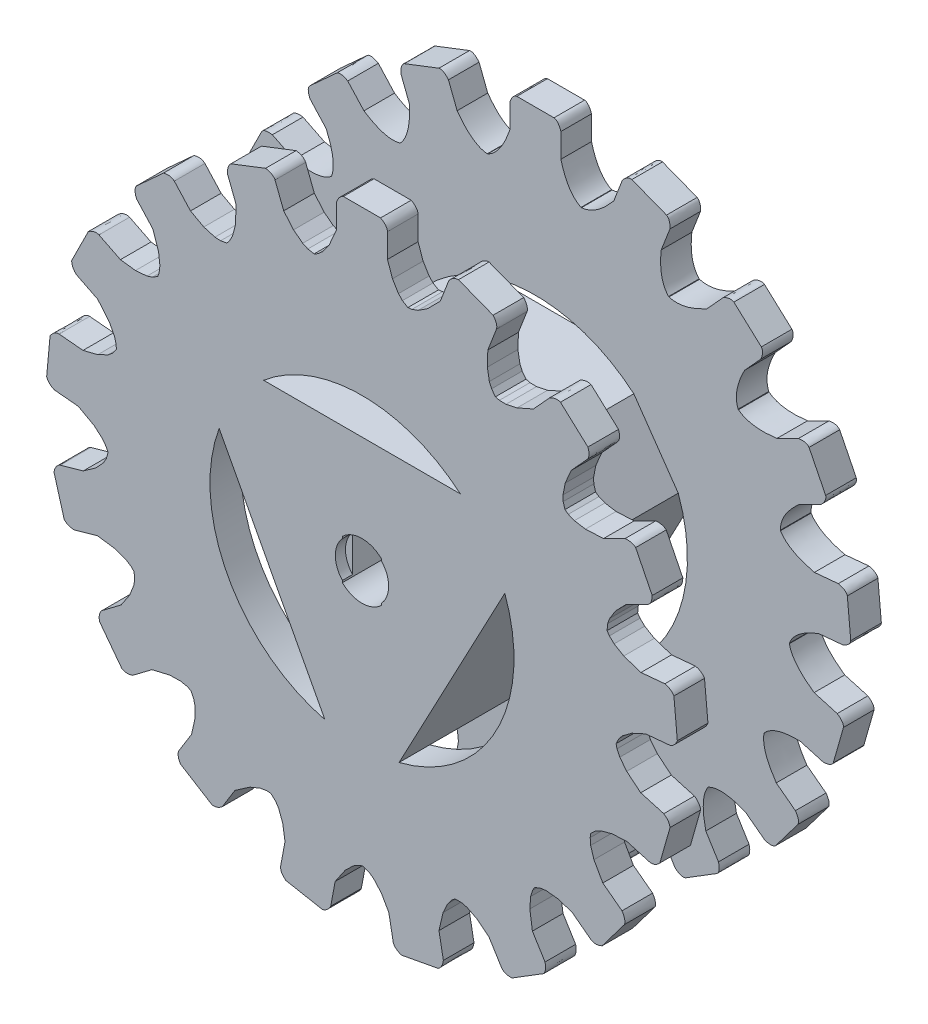
from build123d import *

# Parameters (mm, degrees)
BOSS_EXTRUDE2_DEPTH  = 3
BOSS_EXTRUDE3_DEPTH  = 14
BOSS_EXTRUDE7_DEPTH  = 3
BOSS_EXTRUDE10_DEPTH = 5
CUT_EXTRUDE2_DEPTH   = 6.8
SKETCH7_R            = 2.616026973
CUT_EXTRUDE3_DEPTH   = 1


with BuildPart() as part:
    # Sketch1 → Boss-Extrude2 (new body)
    with BuildSketch(Plane.XY):
        with BuildLine():
            Line((8.523768733, 28.922958261), (7.673117692, 26.727174809))
            add(Edge.make_bspline(
                [(7.673117692, 26.727174809), (5.977966967, 24.70445358), (4.514634253, 24.588982849)],
                knots=[0, 0, 0, 0.37277567, 0.37277567, 0.37277567], degree=2))
            ThreePointArc((4.514634253, 24.588982849), (4.492443696, 24.593046774), (4.470249482, 24.597090673))
            add(Edge.make_bspline(
                [(2.5, 27.6941981), (3.147445202, 25.23338067), (4.470249482, 24.597090673)],
                knots=[0, 0, 0, 0.37277567, 0.37277567, 0.37277567], degree=2))
            Line((2.5, 27.6941981), (2.5, 30.04899579))
            add(Edge.make_bspline(
                [(2.5, 30.04899579), (2.258646097, 30.79207266), (1.822349431, 30.874685911)],
                knots=[0, 0, 0, 0.57378329, 0.57378329, 0.57378329], degree=2))
            Line((1.822349431, 30.874685911), (-1.822349431, 30.874685911))
            add(Edge.make_bspline(
                [(-2.5, 30.04899579), (-2.258646161, 30.79207266), (-1.822349431, 30.874685911)],
                knots=[0, 0, 0, 0.573783349, 0.573783349, 0.573783349], degree=2))
            Line((-2.5, 30.04899579), (-2.5, 27.6941981))
            add(Edge.make_bspline(
                [(-2.5, 27.6941981), (-3.349989788, 25.195707653), (-4.672794068, 24.559417656)],
                knots=[0, 0, 0, 0.37277567, 0.37277567, 0.37277567], degree=2))
            ThreePointArc((-4.672794068, 24.559417656), (-4.694954204, 24.555190999), (-4.717110518, 24.550944348))
            add(Edge.make_bspline(
                [(-7.673117692, 26.727174809), (-6.180443233, 24.666415078), (-4.717110518, 24.550944348)],
                knots=[0, 0, 0, 0.37277567, 0.37277567, 0.37277567], degree=2))
            Line((-7.673117692, 26.727174809), (-8.523768733, 28.922958261))
            add(Edge.make_bspline(
                [(-8.523768733, 28.922958261), (-9.017254872, 29.528669721), (-9.453932744, 29.448095748)],
                knots=[0, 0, 0, 0.57378329, 0.57378329, 0.57378329], degree=2))
            Line((-9.453932744, 29.448095748), (-12.852513218, 28.131478658))
            add(Edge.make_bspline(
                [(-13.18612988, 27.11674993), (-13.229504455, 27.896835539), (-12.852513218, 28.131478658)],
                knots=[0, 0, 0, 0.573783349, 0.573783349, 0.573783349], degree=2))
            Line((-13.18612988, 27.11674993), (-12.335478839, 24.920966478))
            add(Edge.make_bspline(
                [(-12.335478839, 24.920966478), (-12.22551186, 22.284141794), (-13.229135657, 21.21296702)],
                knots=[0, 0, 0, 0.37277567, 0.37277567, 0.37277567], degree=2))
            ThreePointArc((-13.229135657, 21.21296702), (-13.248272524, 21.201020615), (-13.267398604, 21.189056947))
            add(Edge.make_bspline(
                [(-16.809938321, 22.15049846), (-14.673628561, 20.768113448), (-13.267398604, 21.189056947)],
                knots=[0, 0, 0, 0.37277567, 0.37277567, 0.37277567], degree=2))
            Line((-16.809938321, 22.15049846), (-18.396355267, 23.890714952))
            add(Edge.make_bspline(
                [(-18.396355267, 23.890714952), (-19.075325604, 24.277256312), (-19.453408917, 24.044377078)],
                knots=[0, 0, 0, 0.57378329, 0.57378329, 0.57378329], degree=2))
            Line((-19.453408917, 24.044377078), (-22.146873877, 21.588959331))
            add(Edge.make_bspline(
                [(-22.091399853, 20.522236733), (-22.413644864, 21.233976197), (-22.146873877, 21.588959331)],
                knots=[0, 0, 0, 0.573783349, 0.573783349, 0.573783349], degree=2))
            Line((-22.091399853, 20.522236733), (-20.504982907, 18.782020242))
            add(Edge.make_bspline(
                [(-20.504982907, 18.782020242), (-19.449910811, 16.362979105), (-19.99880917, 15.001587642)],
                knots=[0, 0, 0, 0.37277567, 0.37277567, 0.37277567], degree=2))
            ThreePointArc((-19.99880917, 15.001587642), (-20.012338228, 14.983534918), (-20.025850991, 14.965469993))
            add(Edge.make_bspline(
                [(-23.676483633, 14.582274554), (-21.185059044, 14.064963017), (-20.025850991, 14.965469993)],
                knots=[0, 0, 0, 0.37277567, 0.37277567, 0.37277567], degree=2))
            Line((-23.676483633, 14.582274554), (-25.784412084, 15.631898205))
            add(Edge.make_bspline(
                [(-25.784412084, 15.631898205), (-26.557167913, 15.747064912), (-26.82559442, 15.393332048)],
                knots=[0, 0, 0, 0.57378329, 0.57378329, 0.57378329], degree=2))
            Line((-26.82559442, 15.393332048), (-28.450176499, 12.130731418))
            add(Edge.make_bspline(
                [(-28.013103863, 11.156081748), (-28.570698337, 11.703350707), (-28.450176499, 12.130731418)],
                knots=[0, 0, 0, 0.573783349, 0.573783349, 0.573783349], degree=2))
            Line((-28.013103863, 11.156081748), (-25.905175412, 10.106458097))
            add(Edge.make_bspline(
                [(-25.905175412, 10.106458097), (-24.047491531, 8.231905417), (-24.067532687, 6.764160727)],
                knots=[0, 0, 0, 0.37277567, 0.37277567, 0.37277567], degree=2))
            ThreePointArc((-24.067532687, 6.764160727), (-24.073626762, 6.742439803), (-24.079701234, 6.720713389))
            add(Edge.make_bspline(
                [(-27.345388634, 5.044633666), (-24.835329912, 5.462261394), (-24.079701234, 6.720713389)],
                knots=[0, 0, 0, 0.37277567, 0.37277567, 0.37277567], degree=2))
            Line((-27.345388634, 5.044633666), (-29.690141173, 5.261906986))
            add(Edge.make_bspline(
                [(-29.690141173, 5.261906986), (-30.452317537, 5.090145139), (-30.574834751, 4.663332228)],
                knots=[0, 0, 0, 0.57378329, 0.57378329, 0.57378329], degree=2))
            Line((-30.574834751, 4.663332228), (-30.911125136, 1.034181008))
            add(Edge.make_bspline(
                [(-30.15148297, 0.283236104), (-30.869120683, 0.592122854), (-30.911125136, 1.034181008)],
                knots=[0, 0, 0, 0.573783349, 0.573783349, 0.573783349], degree=2))
            Line((-30.15148297, 0.283236104), (-27.806730432, 0.065962785))
            add(Edge.make_bspline(
                [(-27.806730432, 0.065962785), (-25.397325268, -1.010932712), (-24.885802553, -2.386803576)],
                knots=[0, 0, 0, 0.37277567, 0.37277567, 0.37277567], degree=2))
            ThreePointArc((-24.885802553, -2.386803576), (-24.883638606, -2.409259168), (-24.881454396, -2.431712798))
            add(Edge.make_bspline(
                [(-27.321147375, -5.174312952), (-25.131451858, -3.878148898), (-24.881454396, -2.431712798)],
                knots=[0, 0, 0, 0.37277567, 0.37277567, 0.37277567], degree=2))
            Line((-27.321147375, -5.174312952), (-29.586052178, -5.818733929))
            add(Edge.make_bspline(
                [(-29.586052178, -5.818733929), (-30.234712936, -6.25422694), (-30.194774228, -6.69647645)],
                knots=[0, 0, 0, 0.57378329, 0.57378329, 0.57378329], degree=2))
            Line((-30.194774228, -6.69647645), (-29.19735504, -10.202041278))
            add(Edge.make_bspline(
                [(-28.217737227, -10.627862145), (-28.998497229, -10.599074471), (-29.19735504, -10.202041278)],
                knots=[0, 0, 0, 0.573783349, 0.573783349, 0.573783349], degree=2))
            Line((-28.217737227, -10.627862145), (-25.952832424, -9.983441168))
            add(Edge.make_bspline(
                [(-25.952832424, -9.983441168), (-23.317109497, -10.117238776), (-22.343106886, -11.21541683)],
                knots=[0, 0, 0, 0.37277567, 0.37277567, 0.37277567], degree=2))
            ThreePointArc((-22.343106886, -11.21541683), (-22.33297717, -11.235574338), (-22.322829269, -11.255722697))
            add(Edge.make_bspline(
                [(-23.60703377, -14.694439933), (-22.033431972, -12.694793692), (-22.322829269, -11.255722697)],
                knots=[0, 0, 0, 0.37277567, 0.37277567, 0.37277567], degree=2))
            Line((-23.60703377, -14.694439933), (-25.486202894, -16.113522583))
            add(Edge.make_bspline(
                [(-25.486202894, -16.113522583), (-25.933742816, -16.753931016), (-25.736742131, -17.151888877)],
                knots=[0, 0, 0, 0.57378329, 0.57378329, 0.57378329], degree=2))
            Line((-25.736742131, -17.151888877), (-23.540320357, -20.060421358))
            add(Edge.make_bspline(
                [(-22.473029712, -20.10360872), (-23.211466039, -20.358808058), (-23.540320357, -20.060421358)],
                knots=[0, 0, 0, 0.573783349, 0.573783349, 0.573783349], degree=2))
            Line((-22.473029712, -20.10360872), (-20.593860588, -18.68452607))
            add(Edge.make_bspline(
                [(-20.593860588, -18.68452607), (-18.087788883, -17.857155682), (-16.782850827, -18.529325895)],
                knots=[0, 0, 0, 0.37277567, 0.37277567, 0.37277567], degree=2))
            ThreePointArc((-16.782850827, -18.529325895), (-16.766123417, -18.544462936), (-16.749382354, -18.559584876))
            add(Edge.make_bspline(
                [(-16.704659444, -22.230001378), (-15.959675007, -19.796936253), (-16.749382354, -18.559584876)],
                knots=[0, 0, 0, 0.37277567, 0.37277567, 0.37277567], degree=2))
            Line((-16.704659444, -22.230001378), (-17.944300685, -24.232090725))
            add(Edge.make_bspline(
                [(-17.944300685, -24.232090725), (-18.130277025, -24.990923871), (-17.802820396, -25.290843669)],
                knots=[0, 0, 0, 0.57378329, 0.57378329, 0.57378329], degree=2))
            Line((-17.802820396, -25.290843669), (-14.704034968, -27.209530374))
            add(Edge.make_bspline(
                [(-13.693215007, -26.864251539), (-14.28959774, -27.368971804), (-14.704034968, -27.209530374)],
                knots=[0, 0, 0, 0.573783349, 0.573783349, 0.573783349], degree=2))
            Line((-13.693215007, -26.864251539), (-12.453573765, -24.862162192))
            add(Edge.make_bspline(
                [(-12.453573765, -24.862162192), (-10.415612153, -23.185364764), (-8.955977767, -23.340746822)],
                knots=[0, 0, 0, 0.37277567, 0.37277567, 0.37277567], degree=2))
            ThreePointArc((-8.955977767, -23.340746822), (-8.934911792, -23.348819055), (-8.91383854, -23.356872275))
            add(Edge.make_bspline(
                [(-7.546228296, -26.763277955), (-7.730475497, -24.225392875), (-8.91383854, -23.356872275)],
                knots=[0, 0, 0, 0.37277567, 0.37277567, 0.37277567], degree=2))
            Line((-7.546228296, -26.763277955), (-7.978921236, -29.07798074))
            add(Edge.make_bspline(
                [(-7.978921236, -29.07798074), (-7.878216859, -29.852753978), (-7.464529118, -30.014129882)],
                knots=[0, 0, 0, 0.57378329, 0.57378329, 0.57378329], degree=2))
            Line((-7.464529118, -30.014129882), (-3.88188818, -30.683841541))
            add(Edge.make_bspline(
                [(-3.064055738, -29.996728329), (-3.437840086, -30.682804252), (-3.88188818, -30.683841541)],
                knots=[0, 0, 0, 0.573783349, 0.573783349, 0.573783349], degree=2))
            Line((-3.064055738, -29.996728329), (-2.631362798, -27.682025544))
            add(Edge.make_bspline(
                [(-2.631362798, -27.682025544), (-1.336749286, -25.382261859), (0.080449717, -24.999870557)],
                knots=[0, 0, 0, 0.37277567, 0.37277567, 0.37277567], degree=2))
            ThreePointArc((0.080449717, -24.999870557), (0.103009181, -24.999787781), (0.125568562, -24.999684649))
            add(Edge.make_bspline(
                [(2.631362798, -27.682025544), (1.542767565, -25.382075951), (0.125568562, -24.999684649)],
                knots=[0, 0, 0, 0.37277567, 0.37277567, 0.37277567], degree=2))
            Line((2.631362798, -27.682025544), (3.064055738, -29.996728329))
            add(Edge.make_bspline(
                [(3.064055738, -29.996728329), (3.437840149, -30.68280424), (3.88188818, -30.683841541)],
                knots=[0, 0, 0, 0.57378329, 0.57378329, 0.57378329], degree=2))
            Line((3.88188818, -30.683841541), (7.464529118, -30.014129882))
            add(Edge.make_bspline(
                [(7.978921237, -29.07798074), (7.878216922, -29.852753966), (7.464529118, -30.014129882)],
                knots=[0, 0, 0, 0.573783349, 0.573783349, 0.573783349], degree=2))
            Line((7.978921237, -29.07798074), (7.546228296, -26.763277955))
            add(Edge.make_bspline(
                [(7.546228296, -26.763277955), (7.922648978, -24.151143843), (9.106012021, -23.282623243)],
                knots=[0, 0, 0, 0.37277567, 0.37277567, 0.37277567], degree=2))
            ThreePointArc((9.106012021, -23.282623243), (9.127018193, -23.274396639), (9.148016933, -23.266151082))
            add(Edge.make_bspline(
                [(12.453573766, -24.862162192), (10.607651319, -23.110769024), (9.148016933, -23.266151082)],
                knots=[0, 0, 0, 0.37277567, 0.37277567, 0.37277567], degree=2))
            Line((12.453573766, -24.862162192), (13.693215007, -26.864251539))
            add(Edge.make_bspline(
                [(13.693215007, -26.864251539), (14.289597795, -27.36897177), (14.704034968, -27.209530374)],
                knots=[0, 0, 0, 0.57378329, 0.57378329, 0.57378329], degree=2))
            Line((14.704034968, -27.209530374), (17.802820396, -25.290843669))
            add(Edge.make_bspline(
                [(17.944300685, -24.232090725), (18.13027708, -24.990923837), (17.802820396, -25.290843669)],
                knots=[0, 0, 0, 0.573783349, 0.573783349, 0.573783349], degree=2))
            Line((17.944300685, -24.232090725), (16.704659444, -22.230001378))
            add(Edge.make_bspline(
                [(16.704659444, -22.230001378), (16.112049598, -19.658280024), (16.901756944, -18.420928647)],
                knots=[0, 0, 0, 0.37277567, 0.37277567, 0.37277567], degree=2))
            ThreePointArc((16.901756944, -18.420928647), (16.918372824, -18.405669262), (16.934974927, -18.39039489))
            add(Edge.make_bspline(
                [(20.593860588, -18.68452607), (18.239912983, -17.718224678), (16.934974927, -18.39039489)],
                knots=[0, 0, 0, 0.37277567, 0.37277567, 0.37277567], degree=2))
            Line((20.593860588, -18.68452607), (22.473029712, -20.10360872))
            add(Edge.make_bspline(
                [(22.473029712, -20.10360872), (23.211466078, -20.358808006), (23.540320357, -20.060421357)],
                knots=[0, 0, 0, 0.57378329, 0.57378329, 0.57378329], degree=2))
            Line((23.540320357, -20.060421357), (25.736742131, -17.151888877))
            add(Edge.make_bspline(
                [(25.486202894, -16.113522583), (25.933742855, -16.753930964), (25.736742131, -17.151888877)],
                knots=[0, 0, 0, 0.573783349, 0.573783349, 0.573783349], degree=2))
            Line((25.486202894, -16.113522583), (23.60703377, -14.694439933))
            add(Edge.make_bspline(
                [(23.60703377, -14.694439933), (22.125428639, -12.510456558), (22.414825935, -11.071385563)],
                knots=[0, 0, 0, 0.37277567, 0.37277567, 0.37277567], degree=2))
            ThreePointArc((22.414825935, -11.071385563), (22.424807457, -11.051154263), (22.434770717, -11.030913963))
            add(Edge.make_bspline(
                [(25.952832424, -9.983441168), (23.408773328, -9.93273591), (22.434770717, -11.030913963)],
                knots=[0, 0, 0, 0.37277567, 0.37277567, 0.37277567], degree=2))
            Line((25.952832424, -9.983441168), (28.217737227, -10.627862145))
            add(Edge.make_bspline(
                [(28.217737227, -10.627862145), (28.998497247, -10.599074409), (29.19735504, -10.202041278)],
                knots=[0, 0, 0, 0.57378329, 0.57378329, 0.57378329], degree=2))
            Line((29.19735504, -10.202041278), (30.194774228, -6.69647645))
            add(Edge.make_bspline(
                [(29.586052178, -5.818733929), (30.234712953, -6.254226878), (30.194774228, -6.69647645)],
                knots=[0, 0, 0, 0.573783349, 0.573783349, 0.573783349], degree=2))
            Line((29.586052178, -5.818733929), (27.321147375, -5.174312952))
            add(Edge.make_bspline(
                [(27.321147375, -5.174312952), (25.150645941, -3.673026611), (24.900648479, -2.22659051)],
                knots=[0, 0, 0, 0.37277567, 0.37277567, 0.37277567], degree=2))
            ThreePointArc((24.900648479, -2.22659051), (24.902647582, -2.204119643), (24.904626407, -2.181646981))
            add(Edge.make_bspline(
                [(27.806730432, 0.065962785), (25.416149122, -0.805776117), (24.904626407, -2.181646981)],
                knots=[0, 0, 0, 0.37277567, 0.37277567, 0.37277567], degree=2))
            Line((27.806730432, 0.065962785), (30.15148297, 0.283236104))
            add(Edge.make_bspline(
                [(30.15148297, 0.283236104), (30.869120677, 0.592122918), (30.911125136, 1.034181008)],
                knots=[0, 0, 0, 0.57378329, 0.57378329, 0.57378329], degree=2))
            Line((30.911125136, 1.034181008), (30.574834751, 4.663332228))
            add(Edge.make_bspline(
                [(29.690141173, 5.261906986), (30.452317531, 5.090145204), (30.574834751, 4.663332228)],
                knots=[0, 0, 0, 0.573783349, 0.573783349, 0.573783349], degree=2))
            Line((29.690141173, 5.261906986), (27.345388634, 5.044633666))
            add(Edge.make_bspline(
                [(27.345388634, 5.044633666), (24.779129144, 5.660465933), (24.023500467, 6.918917929)],
                knots=[0, 0, 0, 0.37277567, 0.37277567, 0.37277567], degree=2))
            ThreePointArc((24.023500467, 6.918917929), (24.017247161, 6.940593547), (24.010974298, 6.962263514))
            add(Edge.make_bspline(
                [(25.905175412, 10.106458097), (23.990933142, 8.430008204), (24.010974298, 6.962263514)],
                knots=[0, 0, 0, 0.37277567, 0.37277567, 0.37277567], degree=2))
            Line((25.905175412, 10.106458097), (28.013103863, 11.156081748))
            add(Edge.make_bspline(
                [(28.013103863, 11.156081748), (28.570698308, 11.703350765), (28.450176499, 12.130731418)],
                knots=[0, 0, 0, 0.57378329, 0.57378329, 0.57378329], degree=2))
            Line((28.450176499, 12.130731418), (26.82559442, 15.393332048))
            add(Edge.make_bspline(
                [(25.784412084, 15.631898205), (26.557167884, 15.74706497), (26.82559442, 15.393332048)],
                knots=[0, 0, 0, 0.573783349, 0.573783349, 0.573783349], degree=2))
            Line((25.784412084, 15.631898205), (23.676483633, 14.582274554))
            add(Edge.make_bspline(
                [(23.676483633, 14.582274554), (21.061053651, 14.229481187), (19.901845598, 15.129988162)],
                knots=[0, 0, 0, 0.37277567, 0.37277567, 0.37277567], degree=2))
            ThreePointArc((19.901845598, 15.129988162), (19.888184427, 15.14794112), (19.874507062, 15.165881743))
            add(Edge.make_bspline(
                [(20.504982907, 18.782020242), (19.325608703, 16.527273206), (19.874507062, 15.165881743)],
                knots=[0, 0, 0, 0.37277567, 0.37277567, 0.37277567], degree=2))
            Line((20.504982907, 18.782020242), (22.091399853, 20.522236733))
            add(Edge.make_bspline(
                [(22.091399853, 20.522236733), (22.413644816, 21.23397624), (22.146873877, 21.588959331)],
                knots=[0, 0, 0, 0.57378329, 0.57378329, 0.57378329], degree=2))
            Line((22.146873877, 21.588959331), (19.453408917, 24.044377078))
            add(Edge.make_bspline(
                [(18.396355267, 23.890714952), (19.075325556, 24.277256355), (19.453408917, 24.044377078)],
                knots=[0, 0, 0, 0.573783349, 0.573783349, 0.573783349], degree=2))
            Line((18.396355267, 23.890714952), (16.809938321, 22.15049846))
            add(Edge.make_bspline(
                [(16.809938321, 22.15049846), (14.498566159, 20.876726158), (13.092336201, 21.297669657)],
                knots=[0, 0, 0, 0.37277567, 0.37277567, 0.37277567], degree=2))
            ThreePointArc((13.092336201, 21.297669657), (13.073112182, 21.309475307), (13.053877518, 21.321263606))
            add(Edge.make_bspline(
                [(12.335478839, 24.920966478), (12.050253721, 22.39243838), (13.053877518, 21.321263606)],
                knots=[0, 0, 0, 0.37277567, 0.37277567, 0.37277567], degree=2))
            Line((12.335478839, 24.920966478), (13.18612988, 27.11674993))
            add(Edge.make_bspline(
                [(13.18612988, 27.11674993), (13.229504394, 27.896835562), (12.852513218, 28.131478658)],
                knots=[0, 0, 0, 0.57378329, 0.57378329, 0.57378329], degree=2))
            Line((12.852513218, 28.131478658), (9.453932744, 29.448095748))
            add(Edge.make_bspline(
                [(8.523768733, 28.922958261), (9.017254812, 29.528669744), (9.453932744, 29.448095748)],
                knots=[0, 0, 0, 0.573783349, 0.573783349, 0.573783349], degree=2))
        make_face()
        with BuildLine():
            Line((3.634467092, -14.450668417), (14.001693202, 5.09742643))
            ThreePointArc((14.001693202, 5.09742643), (13.163986498, -6.981448863), (3.634467092, -14.450668417))
        make_face(mode=Mode.SUBTRACT)
        with BuildLine():
            Line((-9.644278202, 11.358656025), (9.644278202, 11.358656025))
            ThreePointArc((9.644278202, 11.358656025), (0, 14.900710343), (-9.644278202, 11.358656025))
        make_face(mode=Mode.SUBTRACT)
        with BuildLine():
            Line((-14.001693202, 5.09742643), (-3.634467092, -14.450668417))
            ThreePointArc((-3.634467092, -14.450668417), (-13.163986498, -6.981448863), (-14.001693202, 5.09742643))
        make_face(mode=Mode.SUBTRACT)
    extrude(amount=BOSS_EXTRUDE2_DEPTH)

    # Sketch2 → Boss-Extrude3 (add)
    with BuildSketch(Plane.XY.offset(3)):
        Polygon((-14.001693202, 5.09742643), (-9.644278202, 11.358656025), (9.644278202, 11.358656025), (14.001693202, 5.09742643), (3.634467092, -14.450668417), (-3.634467092, -14.450668417), align=None)
    extrude(amount=BOSS_EXTRUDE3_DEPTH)

    # Sketch3 → Boss-Extrude7 (add)
    with BuildSketch(Plane.XY.offset(17)):
        with BuildLine():
            Line((-4.337121054, 24.756139353), (-4.694161258, 24.56333699))
            Line((-4.694161258, 24.56333699), (-5.304764946, 24.675338609))
            Line((-5.304764946, 24.675338609), (-5.810986873, 24.906675757))
            Line((-5.810986873, 24.906675757), (-6.709155754, 25.596214612))
            Line((-6.709155754, 25.596214612), (-7.673117692, 26.727174809))
            Line((-7.673117692, 26.727174809), (-8.523768733, 28.922958261))
            add(Edge.make_bspline(
                [(-9.453932744, 29.448095748), (-8.75385581, 29.362411901), (-8.523768733, 28.922958261)],
                knots=[0, 0, 0, 0.68826063, 0.68826063, 0.68826063], degree=2))
            Line((-9.453932744, 29.448095748), (-12.852513218, 28.131478659))
            add(Edge.make_bspline(
                [(-13.18612988, 27.11674993), (-13.216879175, 27.779302095), (-12.852513218, 28.131478658)],
                knots=[0, 0, 0, 0.746925203, 0.746925203, 0.746925203], degree=2))
            Line((-13.18612988, 27.11674993), (-12.335478839, 24.920966478))
            Line((-12.335478839, 24.920966478), (-12.411941504, 23.148059769))
            Line((-12.411941504, 23.148059769), (-12.689350854, 22.087109535))
            Line((-12.689350854, 22.087109535), (-12.987193967, 21.517663618))
            Line((-12.987193967, 21.517663618), (-13.250475795, 21.208902971))
            Line((-13.250475795, 21.208902971), (-13.860306428, 21.092765877))
            Line((-13.860306428, 21.092765877), (-14.415912935, 21.12561289))
            Line((-14.415912935, 21.12561289), (-15.502520638, 21.4441327))
            Line((-15.502520638, 21.4441327), (-16.809938321, 22.15049846))
            Line((-16.809938321, 22.15049846), (-18.396355267, 23.890714952))
            add(Edge.make_bspline(
                [(-19.453408917, 24.044377078), (-18.769654041, 24.217376227), (-18.396355267, 23.890714952)],
                knots=[0, 0, 0, 0.68826063, 0.68826063, 0.68826063], degree=2))
            Line((-19.453408917, 24.044377078), (-22.146873877, 21.588959332))
            add(Edge.make_bspline(
                [(-22.091399853, 20.522236733), (-22.359414165, 21.128940301), (-22.146873877, 21.588959331)],
                knots=[0, 0, 0, 0.746925203, 0.746925203, 0.746925203], degree=2))
            Line((-22.091399853, 20.522236733), (-20.504982907, 18.782020242))
            Line((-20.504982907, 18.782020242), (-19.935834446, 17.10121247))
            Line((-19.935834446, 17.10121247), (-19.811251531, 16.011694024))
            Line((-19.811251531, 16.011694024), (-19.88327437, 15.373108178))
            Line((-19.88327437, 15.373108178), (-20.017240152, 14.990089082))
            Line((-20.017240152, 14.990089082), (-20.543936725, 14.661498233))
            Line((-20.543936725, 14.661498233), (-21.073890073, 14.491418941))
            Line((-21.073890073, 14.491418941), (-22.202184207, 14.395901841))
            Line((-22.202184207, 14.395901841), (-23.676483633, 14.582274554))
            Line((-23.676483633, 14.582274554), (-25.784412084, 15.631898205))
            add(Edge.make_bspline(
                [(-26.82559442, 15.393332048), (-26.250506488, 15.801649701), (-25.784412084, 15.631898205)],
                knots=[0, 0, 0, 0.68826063, 0.68826063, 0.68826063], degree=2))
            Line((-26.82559442, 15.393332048), (-28.450176499, 12.130731418))
            add(Edge.make_bspline(
                [(-28.013103863, 11.156081748), (-28.482186373, 11.62499804), (-28.450176499, 12.130731418)],
                knots=[0, 0, 0, 0.746925203, 0.746925203, 0.746925203], degree=2))
            Line((-28.013103863, 11.156081748), (-25.905175412, 10.106458097))
            Line((-25.905175412, 10.106458097), (-24.767282477, 8.744751665))
            Line((-24.767282477, 8.744751665), (-24.25753291, 7.773810511))
            Line((-24.25753291, 7.773810511), (-24.094008392, 7.152329293))
            Line((-24.094008392, 7.152329293), (-24.080565308, 6.746780601))
            Line((-24.080565308, 6.746780601), (-24.452994529, 6.250114011))
            Line((-24.452994529, 6.250114011), (-24.885721582, 5.900078564))
            Line((-24.885721582, 5.900078564), (-25.903319773, 5.403424668))
            Line((-25.903319773, 5.403424668), (-27.345388634, 5.044633666))
            Line((-27.345388634, 5.044633666), (-29.690141173, 5.261906986))
            add(Edge.make_bspline(
                [(-30.574834751, 4.663332228), (-30.186082574, 5.251822823), (-29.690141173, 5.261906986)],
                knots=[0, 0, 0, 0.68826063, 0.68826063, 0.68826063], degree=2))
            Line((-30.574834751, 4.663332228), (-30.911125136, 1.034181008))
            add(Edge.make_bspline(
                [(-30.15148297, 0.283236104), (-30.758281487, 0.551035377), (-30.911125136, 1.034181008)],
                knots=[0, 0, 0, 0.746925203, 0.746925203, 0.746925203], degree=2))
            Line((-30.15148297, 0.283236104), (-27.806730432, 0.065962785))
            Line((-27.806730432, 0.065962785), (-26.25377177, -0.792736308))
            Line((-26.25377177, -0.792736308), (-25.427700054, -1.513969188))
            Line((-25.427700054, -1.513969188), (-25.050713072, -2.034411296))
            Line((-25.050713072, -2.034411296), (-24.891676683, -2.407717987))
            Line((-24.891676683, -2.407717987), (-25.059539924, -3.005382741))
            Line((-25.059539924, -3.005382741), (-25.336598495, -3.488100116))
            Line((-25.336598495, -3.488100116), (-26.106068468, -4.318814948))
            Line((-26.106068468, -4.318814948), (-27.321147375, -5.174312952))
            Line((-27.321147375, -5.174312952), (-29.586052178, -5.818733929))
            add(Edge.make_bspline(
                [(-30.194774228, -6.69647645), (-30.044860942, -6.007291828), (-29.586052178, -5.818733929)],
                knots=[0, 0, 0, 0.68826063, 0.68826063, 0.68826063], degree=2))
            Line((-30.194774228, -6.69647645), (-29.19735504, -10.202041277))
            add(Edge.make_bspline(
                [(-28.217737227, -10.627862144), (-28.880300249, -10.597347667), (-29.197355039, -10.202041278)],
                knots=[0, 0, 0, 0.746925203, 0.746925203, 0.746925203], degree=2))
            Line((-28.217737227, -10.627862145), (-25.952832424, -9.983441168))
            Line((-25.952832424, -9.983441168), (-24.194543707, -10.22316085))
            Line((-24.194543707, -10.22316085), (-23.163715406, -10.597278959))
            Line((-23.163715406, -10.597278959), (-22.62418014, -10.946393366))
            Line((-22.62418014, -10.946393366), (-22.341029193, -11.237040918))
            Line((-22.341029193, -11.237040918), (-22.281655592, -11.8549859))
            Line((-22.281655592, -11.8549859), (-22.365627386, -12.405191548))
            Line((-22.365627386, -12.405191548), (-22.783047957, -13.457774674))
            Line((-22.783047957, -13.457774674), (-23.60703377, -14.694439933))
            Line((-23.60703377, -14.694439933), (-25.486202894, -16.113522583))
            add(Edge.make_bspline(
                [(-25.73674213, -17.151888877), (-25.845914356, -16.455088431), (-25.486202894, -16.113522583)],
                knots=[0, 0, 0, 0.68826063, 0.68826063, 0.68826063], degree=2))
            Line((-25.736742131, -17.151888877), (-23.540320357, -20.060421357))
            add(Edge.make_bspline(
                [(-22.473029712, -20.10360872), (-23.10187443, -20.314500187), (-23.540320357, -20.060421357)],
                knots=[0, 0, 0, 0.746925203, 0.746925203, 0.746925203], degree=2))
            Line((-22.473029712, -20.10360872), (-20.593860588, -18.68452607))
            Line((-20.593860588, -18.68452607), (-18.867708451, -18.272890871))
            Line((-18.867708451, -18.272890871), (-17.771342637, -18.249367484))
            Line((-17.771342637, -18.249367484), (-17.142126315, -18.380004356))
            Line((-17.142126315, -18.380004356), (-16.773101915, -18.548739207))
            Line((-16.773101915, -18.548739207), (-16.494510205, -19.103507524))
            Line((-16.494510205, -19.103507524), (-16.374054367, -19.646893121))
            Line((-16.374054367, -19.646893121), (-16.383050575, -20.779187358))
            Line((-16.383050575, -20.779187358), (-16.704659444, -22.230001378))
            Line((-16.704659444, -22.230001378), (-17.944300685, -24.232090725))
            add(Edge.make_bspline(
                [(-17.802820396, -25.290843669), (-18.156333818, -24.68053416), (-17.944300685, -24.232090725)],
                knots=[0, 0, 0, 0.68826063, 0.68826063, 0.68826063], degree=2))
            Line((-17.802820396, -25.290843669), (-14.704034969, -27.209530374))
            add(Edge.make_bspline(
                [(-13.693215007, -26.864251539), (-14.203412458, -27.28806689), (-14.704034968, -27.209530374)],
                knots=[0, 0, 0, 0.746925203, 0.746925203, 0.746925203], degree=2))
            Line((-13.693215007, -26.864251539), (-12.453573765, -24.862162192))
            Line((-12.453573765, -24.862162192), (-10.992684619, -23.854765726))
            Line((-10.992684619, -23.854765726), (-9.978851572, -23.436777808))
            Line((-9.978851572, -23.436777808), (-9.344933344, -23.33129391))
            Line((-9.344933344, -23.33129391), (-8.93987428, -23.355327484))
            Line((-8.93987428, -23.355327484), (-8.479689816, -23.771994599))
            Line((-8.479689816, -23.771994599), (-8.171074574, -24.235172911))
            Line((-8.171074574, -24.235172911), (-7.770431431, -25.294255648))
            Line((-7.770431431, -25.294255648), (-7.546228296, -26.763277955))
            Line((-7.546228296, -26.763277955), (-7.978921237, -29.07798074))
            add(Edge.make_bspline(
                [(-7.464529118, -30.014129882), (-8.014639791, -29.572736992), (-7.978921236, -29.077980739)],
                knots=[0, 0, 0, 0.68826063, 0.68826063, 0.68826063], degree=2))
            Line((-7.464529118, -30.014129882), (-3.88188818, -30.683841541))
            add(Edge.make_bspline(
                [(-3.064055738, -29.996728329), (-3.38670093, -30.576228951), (-3.881888179, -30.683841541)],
                knots=[0, 0, 0, 0.746925203, 0.746925203, 0.746925203], degree=2))
            Line((-3.064055738, -29.996728329), (-2.631362798, -27.682025544))
            Line((-2.631362798, -27.682025544), (-1.633037816, -26.214922286))
            Line((-1.633037816, -26.214922286), (-0.838661307, -25.458921421))
            Line((-0.838661307, -25.458921421), (-0.285655343, -25.131562939))
            Line((-0.285655343, -25.131562939), (0.100732914, -25.007649367))
            Line((0.100732914, -25.007649367), (0.68035967, -25.229942079))
            Line((0.68035967, -25.229942079), (1.135454118, -25.550358308))
            Line((1.135454118, -25.550358308), (1.891627535, -26.393194552))
            Line((1.891627535, -26.393194552), (2.631362798, -27.682025544))
            Line((2.631362798, -27.682025544), (3.064055738, -29.996728329))
            add(Edge.make_bspline(
                [(3.88188818, -30.683841541), (3.209475751, -30.470977824), (3.064055738, -29.996728329)],
                knots=[0, 0, 0, 0.68826063, 0.68826063, 0.68826063], degree=2))
            Line((3.88188818, -30.683841541), (7.464529118, -30.014129882))
            add(Edge.make_bspline(
                [(7.978921237, -29.077980739), (7.887403326, -29.734901863), (7.464529118, -30.014129882)],
                knots=[0, 0, 0, 0.746925203, 0.746925203, 0.746925203], degree=2))
            Line((7.978921237, -29.07798074), (7.546228296, -26.763277955))
            Line((7.546228296, -26.763277955), (7.947159792, -25.03460833))
            Line((7.947159792, -25.03460833), (8.414794815, -24.042696624))
            Line((8.414794815, -24.042696624), (8.812201996, -23.537675134))
            Line((8.812201996, -23.537675134), (9.12773557, -23.282549632))
            Line((9.12773557, -23.282549632), (9.748522813, -23.280446078))
            Line((9.748522813, -23.280446078), (10.28863344, -23.414826236))
            Line((10.28863344, -23.414826236), (11.298211721, -23.927586283))
            Line((11.298211721, -23.927586283), (12.453573765, -24.862162192))
            Line((12.453573765, -24.862162192), (13.693215007, -26.864251539))
            add(Edge.make_bspline(
                [(14.704034968, -27.209530374), (14.000133808, -27.253944256), (13.693215007, -26.864251539)],
                knots=[0, 0, 0, 0.68826063, 0.68826063, 0.68826063], degree=2))
            Line((14.704034968, -27.209530374), (17.802820396, -25.290843669))
            add(Edge.make_bspline(
                [(17.944300685, -24.232090725), (18.096270056, -24.877711512), (17.802820396, -25.290843669)],
                knots=[0, 0, 0, 0.746925203, 0.746925203, 0.746925203], degree=2))
            Line((17.944300685, -24.232090725), (16.704659444, -22.230001378))
            Line((16.704659444, -22.230001378), (16.454049434, -20.473231796))
            Line((16.454049434, -20.473231796), (16.531786269, -19.379372422))
            Line((16.531786269, -19.379372422), (16.719922624, -18.764893876))
            Line((16.719922624, -18.764893876), (16.921986959, -18.413012556))
            Line((16.921986959, -18.413012556), (17.500093932, -18.186796832))
            Line((17.500093932, -18.186796832), (18.052275804, -18.116992135))
            Line((18.052275804, -18.116992135), (19.178909808, -18.230424898))
            Line((19.178909808, -18.230424898), (20.593860588, -18.68452607))
            Line((20.593860588, -18.68452607), (22.473029712, -20.10360872))
            add(Edge.make_bspline(
                [(23.540320357, -20.060421357), (22.899996217, -20.356114497), (22.473029712, -20.10360872)],
                knots=[0, 0, 0, 0.68826063, 0.68826063, 0.68826063], degree=2))
            Line((23.540320357, -20.060421358), (25.73674213, -17.151888877))
            add(Edge.make_bspline(
                [(25.486202894, -16.113522583), (25.861135241, -16.660648369), (25.736742131, -17.151888877)],
                knots=[0, 0, 0, 0.746925203, 0.746925203, 0.746925203], degree=2))
            Line((25.486202894, -16.113522583), (23.60703377, -14.694439933))
            Line((23.60703377, -14.694439933), (22.738728525, -13.146831863))
            Line((22.738728525, -13.146831863), (22.416068382, -12.09875659))
            Line((22.416068382, -12.09875659), (22.369525054, -11.457809719))
            Line((22.369525054, -11.457809719), (22.43083024, -11.056696104))
            Line((22.43083024, -11.056696104), (22.888180393, -10.636919897))
            Line((22.888180393, -10.636919897), (23.37785829, -10.372357856))
            Line((23.37785829, -10.372357856), (24.469389852, -10.071143613))
            Line((24.469389852, -10.071143613), (25.952832424, -9.983441168))
            Line((25.952832424, -9.983441168), (28.217737227, -10.627862145))
            add(Edge.make_bspline(
                [(29.197355039, -10.202041278), (28.707087244, -10.709078677), (28.217737227, -10.627862144)],
                knots=[0, 0, 0, 0.68826063, 0.68826063, 0.68826063], degree=2))
            Line((29.19735504, -10.202041278), (30.194774228, -6.69647645))
            add(Edge.make_bspline(
                [(29.586052178, -5.818733929), (30.13331081, -6.193472344), (30.194774228, -6.69647645)],
                knots=[0, 0, 0, 0.746925203, 0.746925203, 0.746925203], degree=2))
            Line((29.586052178, -5.818733929), (27.321147375, -5.174312952))
            Line((27.321147375, -5.174312952), (25.952416329, -4.044879438))
            Line((25.952416329, -4.044879438), (25.272936248, -3.184136639))
            Line((25.272936248, -3.184136639), (24.997999172, -2.603284871))
            Line((24.997999172, -2.603284871), (24.910265605, -2.207111576))
            Line((24.910265605, -2.207111576), (25.185091265, -1.650467989))
            Line((25.185091265, -1.650467989), (25.546131473, -1.226879173))
            Line((25.546131473, -1.226879173), (26.455143207, -0.551698577))
            Line((26.455143207, -0.551698577), (27.806730432, 0.065962785))
            Line((27.806730432, 0.065962785), (30.15148297, 0.283236104))
            add(Edge.make_bspline(
                [(30.911125136, 1.034181008), (30.637127067, 0.384277558), (30.15148297, 0.283236104)],
                knots=[0, 0, 0, 0.68826063, 0.68826063, 0.68826063], degree=2))
            Line((30.911125136, 1.034181008), (30.574834751, 4.663332228))
            add(Edge.make_bspline(
                [(29.690141173, 5.261906986), (30.335815779, 5.11016644), (30.574834751, 4.663332228)],
                knots=[0, 0, 0, 0.746925203, 0.746925203, 0.746925203], degree=2))
            Line((29.690141173, 5.261906986), (27.345388634, 5.044633666))
            Line((27.345388634, 5.044633666), (25.6610865, 5.603356369))
            Line((25.6610865, 5.603356369), (24.716554031, 6.16051861))
            Line((24.716554031, 6.16051861), (24.250354983, 6.602828025))
            Line((24.250354983, 6.602828025), (24.025431567, 6.940555601))
            Line((24.025431567, 6.940555601), (24.080616006, 7.558888766))
            Line((24.080616006, 7.558888766), (24.264258044, 8.08429634))
            Line((24.264258044, 8.08429634), (24.867982878, 9.042256409))
            Line((24.867982878, 9.042256409), (25.905175412, 10.106458097))
            Line((25.905175412, 10.106458097), (28.013103863, 11.156081748))
            add(Edge.make_bspline(
                [(28.450176499, 12.130731418), (28.429453113, 11.42573498), (28.013103863, 11.156081748)],
                knots=[0, 0, 0, 0.68826063, 0.68826063, 0.68826063], degree=2))
            Line((28.450176499, 12.130731418), (26.82559442, 15.393332048))
            add(Edge.make_bspline(
                [(25.784412084, 15.631898205), (26.441300731, 15.72364893), (26.82559442, 15.393332048)],
                knots=[0, 0, 0, 0.746925203, 0.746925203, 0.746925203], degree=2))
            Line((25.784412084, 15.631898205), (23.676483633, 14.582274554))
            Line((23.676483633, 14.582274554), (21.904084747, 14.494827849))
            Line((21.904084747, 14.494827849), (20.822064234, 14.673161683))
            Line((20.822064234, 14.673161683), (20.227565977, 14.917192409))
            Line((20.227565977, 14.917192409), (19.895829866, 15.150862284))
            Line((19.895829866, 15.150862284), (19.72392012, 15.747375708))
            Line((19.72392012, 15.747375708), (19.705362113, 16.303642836))
            Line((19.705362113, 16.303642836), (19.922263664, 17.415004563))
            Line((19.922263664, 17.415004563), (20.504982907, 18.782020242))
            Line((20.504982907, 18.782020242), (22.091399853, 20.522236733))
            add(Edge.make_bspline(
                [(22.146873877, 21.588959331), (22.382223984, 20.924083581), (22.091399853, 20.522236733)],
                knots=[0, 0, 0, 0.68826063, 0.68826063, 0.68826063], degree=2))
            Line((22.146873877, 21.588959331), (19.453408917, 24.044377077))
            add(Edge.make_bspline(
                [(18.396355267, 23.890714952), (18.975741503, 24.213565505), (19.453408917, 24.044377078)],
                knots=[0, 0, 0, 0.746925203, 0.746925203, 0.746925203], degree=2))
            Line((18.396355267, 23.890714952), (16.809938321, 22.15049846))
            Line((16.809938321, 22.15049846), (15.188814973, 21.42869251))
            Line((15.188814973, 21.42869251), (14.115439282, 21.204112964))
            Line((14.115439282, 21.204112964), (13.472932102, 21.216907298))
            Line((13.472932102, 21.216907298), (13.079186095, 21.314961062))
            Line((13.079186095, 21.314961062), (12.703399528, 21.809092302))
            Line((12.703399528, 21.809092302), (12.485147838, 22.321092025))
            Line((12.485147838, 22.321092025), (12.285932349, 23.43575985))
            Line((12.285932349, 23.43575985), (12.335478839, 24.920966478))
            Line((12.335478839, 24.920966478), (13.18612988, 27.11674993))
            add(Edge.make_bspline(
                [(12.852513218, 28.131478658), (13.312151481, 27.59651875), (13.18612988, 27.11674993)],
                knots=[0, 0, 0, 0.68826063, 0.68826063, 0.68826063], degree=2))
            Line((12.852513218, 28.131478658), (9.453932745, 29.448095748))
            add(Edge.make_bspline(
                [(8.523768733, 28.922958261), (8.947403237, 29.433305886), (9.453932744, 29.448095748)],
                knots=[0, 0, 0, 0.746925203, 0.746925203, 0.746925203], degree=2))
            Line((8.523768733, 28.922958261), (7.673117692, 26.727174809))
            Line((7.673117692, 26.727174809), (6.422211574, 25.468493506))
            Line((6.422211574, 25.468493506), (5.502446039, 24.871331293))
            Line((5.502446039, 24.871331293), (4.89870409, 24.65116129))
            Line((4.89870409, 24.65116129), (4.496125768, 24.600356239))
            Line((4.496125768, 24.600356239), (3.967214437, 24.925370132))
            Line((3.967214437, 24.925370132), (3.578745165, 25.323954051))
            Line((3.578745165, 25.323954051), (2.990317791, 26.291385907))
            Line((2.990317791, 26.291385907), (2.5, 27.6941981))
            Line((2.5, 27.6941981), (2.5, 30.04899579))
            add(Edge.make_bspline(
                [(1.822349431, 30.874685911), (2.444199155, 30.541891144), (2.5, 30.04899579)],
                knots=[0, 0, 0, 0.68826063, 0.68826063, 0.68826063], degree=2))
            Line((1.822349431, 30.874685911), (-1.822349431, 30.874685911))
            add(Edge.make_bspline(
                [(-2.5, 30.04899579), (-2.289331416, 30.677915211), (-1.822349431, 30.874685911)],
                knots=[0, 0, 0, 0.746925203, 0.746925203, 0.746925203], degree=2))
            Line((-2.5, 30.04899579), (-2.5, 27.6941981))
            Line((-2.5, 27.6941981), (-3.211747086, 26.068633329))
            Line((-3.211747086, 26.068633329), (-3.853683031, 25.179538515))
            Line((-3.853683031, 25.179538515), (-4.337121054, 24.756139353))
        make_face()
        with BuildLine():
            ThreePointArc((-3.634467092, -14.450668417), (-13.163986498, -6.981448863), (-14.001693202, 5.09742643))
            Line((-14.001693202, 5.09742643), (-3.634467092, -14.450668417))
        make_face(mode=Mode.SUBTRACT)
        with BuildLine():
            ThreePointArc((14.001693202, 5.09742643), (13.163986498, -6.981448863), (3.634467092, -14.450668417))
            Line((3.634467092, -14.450668417), (14.001693202, 5.09742643))
        make_face(mode=Mode.SUBTRACT)
        with BuildLine():
            Line((9.644278202, 11.358656025), (-9.644278202, 11.358656025))
            ThreePointArc((-9.644278202, 11.358656025), (0, 14.900710343), (9.644278202, 11.358656025))
        make_face(mode=Mode.SUBTRACT)
    extrude(amount=BOSS_EXTRUDE7_DEPTH)

    # Sketch8 → Boss-Extrude10 (add)
    with BuildSketch(Plane(origin=(0, 0, 0), x_dir=(-1, 0, 0), z_dir=(0, 0, -1))):
        Polygon((0, -5.992650485), (5.189787556, -2.996325242), (5.189787556, 2.996325242), (0, 5.992650485), (-5.189787556, 2.996325242), (-5.189787556, -2.996325242), align=None)
    extrude(amount=BOSS_EXTRUDE10_DEPTH)

    # Sketch6 → Cut-Extrude2 (cut)
    with BuildSketch(Plane.XY.offset(20)):
        with BuildLine():
            ThreePointArc((1.923869798, 1.965), (0, 2.75), (-1.923869798, 1.965))
            Line((-1.923869798, 1.965), (-1.923869798, -1.965))
            ThreePointArc((-1.923869798, -1.965), (0, -2.75), (1.923869798, -1.965))
            Line((1.923869798, -1.965), (1.923869798, 1.965))
        make_face()
    extrude(amount=-CUT_EXTRUDE2_DEPTH, mode=Mode.SUBTRACT)

    # Sketch7 → Cut-Extrude3 (cut)
    with BuildSketch(Plane.XY.offset(20)):
        Circle(SKETCH7_R)
    extrude(amount=-CUT_EXTRUDE3_DEPTH, mode=Mode.SUBTRACT)


solid = part.part
